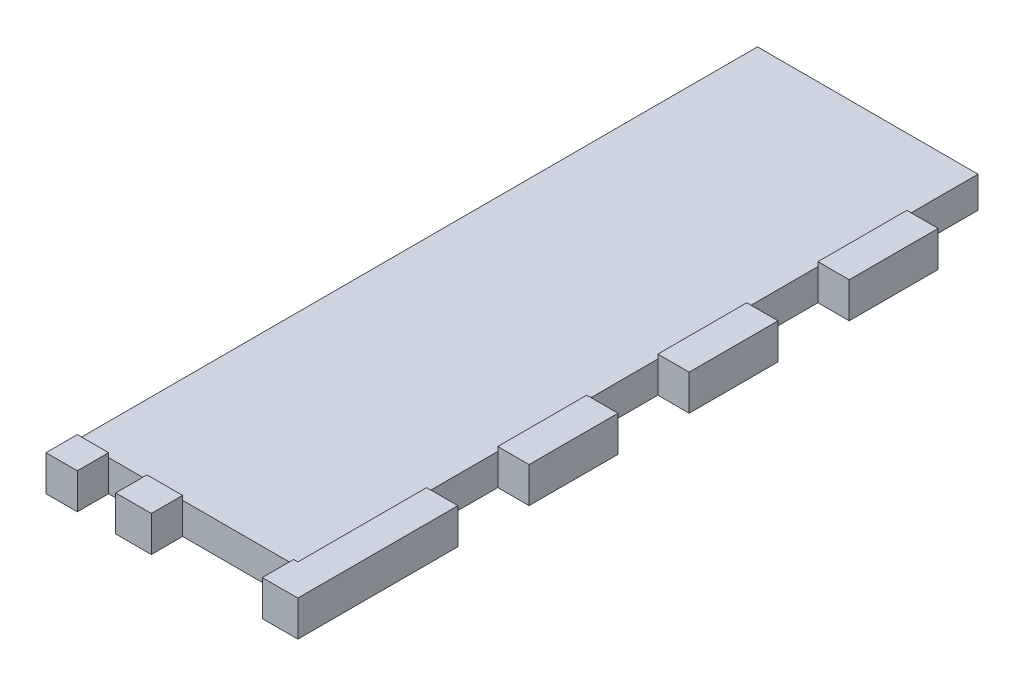
from build123d import *

# Parameters (mm, degrees)
SKETCH1_W           = 44.958
SKETCH1_H           = 304.8
BOSS_EXTRUDE1_DEPTH = 5.588
SKETCH2_W           = 5.588
SKETCH2_H           = 101.6
BOSS_EXTRUDE2_DEPTH = 5.588
SKETCH3_W           = 121.412
SKETCH3_H           = 5.588
BOSS_EXTRUDE3_DEPTH = 39.37
SKETCH7_W           = 332.610738736
SKETCH7_H           = 323.725005723
CUT_EXTRUDE1_DEPTH  = 45.958
SKETCH4_W           = 5.588
SKETCH4_H           = 12.7
CUT_EXTRUDE2_DEPTH  = 6.35
SKETCH8_W           = 6.858
SKETCH8_H           = 5.588
SKETCH8_W_2         = 19.812
CUT_EXTRUDE4_DEPTH  = 7.35


with BuildPart() as part:
    # Sketch1 → Boss-Extrude1 (new body)
    with BuildSketch(Plane.XY):
        with Locations((-6.477, 3.048)):
            Rectangle(SKETCH1_W, SKETCH1_H)
        with BuildLine():
            Line((-3.302, 133.858), (-3.302, -143.002))
            Line((-3.302, -143.002), (3.302, -143.002))
            Line((3.302, -143.002), (3.302, 143.002))
            Line((3.302, 143.002), (-16.256, 143.002))
            Line((-16.256, 143.002), (-16.256, 136.398))
            Line((-16.256, 136.398), (-5.842, 136.398))
            ThreePointArc((-5.842, 136.398), (-4.045948776, 135.654051224), (-3.302, 133.858))
        make_face(mode=Mode.SUBTRACT)
    extrude(amount=BOSS_EXTRUDE1_DEPTH)

    # Sketch2 → Boss-Extrude2 (add)
    with BuildSketch(Plane(origin=(16.002, 0, 0), x_dir=(0, 0, -1), z_dir=(1, 0, 0))):
        Polygon((121.412, -60.452), (121.412, -47.752), (0, -47.752), (0, -149.352), (121.412, -149.352), (121.412, -136.652), (127, -136.652), (127, -119.718666667), (121.412, -119.718666667), (121.412, -107.018666667), (127, -107.018666667), (127, -90.085333333), (121.412, -90.085333333), (121.412, -77.385333333), (127, -77.385333333), (127, -60.452), align=None)
        with BuildLine():
            ThreePointArc((11.4, -116.592), (9.9, -118.092), (8.4, -116.592))
            Line((8.4, -116.592), (8.4, -111.512))
            ThreePointArc((8.4, -111.512), (9.9, -110.012), (11.4, -111.512))
            Line((11.4, -111.512), (11.4, -116.592))
        make_face(mode=Mode.SUBTRACT)
        with BuildLine():
            Line((42.4, -111.512), (42.4, -116.592))
            ThreePointArc((42.4, -116.592), (40.9, -118.092), (39.4, -116.592))
            Line((39.4, -116.592), (39.4, -111.512))
            ThreePointArc((39.4, -111.512), (40.9, -110.012), (42.4, -111.512))
        make_face(mode=Mode.SUBTRACT)
        with BuildLine():
            ThreePointArc((36.4, -101.092), (25.4, -112.092), (14.4, -101.092))
            Line((14.4, -101.092), (14.4, -96.012))
            ThreePointArc((14.4, -96.012), (25.4, -85.012), (36.4, -96.012))
            Line((36.4, -96.012), (36.4, -101.092))
        make_face(mode=Mode.SUBTRACT)
        with BuildLine():
            ThreePointArc((11.4, -85.592), (9.9, -87.092), (8.4, -85.592))
            Line((8.4, -85.592), (8.4, -80.512))
            ThreePointArc((8.4, -80.512), (9.9, -79.012), (11.4, -80.512))
            Line((11.4, -80.512), (11.4, -85.592))
        make_face(mode=Mode.SUBTRACT)
        with BuildLine():
            ThreePointArc((42.4, -85.592), (40.9, -87.092), (39.4, -85.592))
            Line((39.4, -85.592), (39.4, -80.512))
            ThreePointArc((39.4, -80.512), (40.9, -79.012), (42.4, -80.512))
            Line((42.4, -80.512), (42.4, -85.592))
        make_face(mode=Mode.SUBTRACT)
        with Locations((-2.794, -98.552)):
            Rectangle(SKETCH2_W, SKETCH2_H)
    extrude(amount=-BOSS_EXTRUDE2_DEPTH)

    # Sketch3 → Boss-Extrude3 (add)
    with BuildSketch(Plane.ZY.offset(-10.414)):
        with Locations((-60.706, -146.558)):
            Rectangle(SKETCH3_W, SKETCH3_H)
    extrude(amount=BOSS_EXTRUDE3_DEPTH)

    # Sketch7 → Cut-Extrude1 (cut, through all)
    with BuildSketch(Plane(origin=(16.002, 0, 0), x_dir=(0, 0, -1), z_dir=(1, 0, 0))):
        with Locations((160.717369368, 18.860502861)):
            Rectangle(SKETCH7_W, SKETCH7_H)
    extrude(amount=-CUT_EXTRUDE1_DEPTH, mode=Mode.SUBTRACT)

    # Sketch4 → Cut-Extrude2 (cut)
    with BuildSketch(Plane.XZ.offset(149.352)):
        with Locations((13.208, -29.337)):
            Rectangle(SKETCH4_W, SKETCH4_H)
        with Locations((13.208, -57.912)):
            Rectangle(SKETCH4_W, SKETCH4_H)
        with Locations((13.208, -86.487)):
            Rectangle(SKETCH4_W, SKETCH4_H)
        with Locations((13.208, -115.062)):
            Rectangle(SKETCH4_W, SKETCH4_H)
    extrude(amount=-CUT_EXTRUDE2_DEPTH, mode=Mode.SUBTRACT)

    # Sketch8 → Cut-Extrude4 (cut, through all)
    with BuildSketch(Plane.XZ.offset(149.352)):
        with Locations((-19.939, 2.794)):
            Rectangle(SKETCH8_W, SKETCH8_H)
        with Locations((-0.254, 2.794)):
            Rectangle(SKETCH8_W_2, SKETCH8_H)
    extrude(amount=-CUT_EXTRUDE4_DEPTH, mode=Mode.SUBTRACT)


solid = part.part
